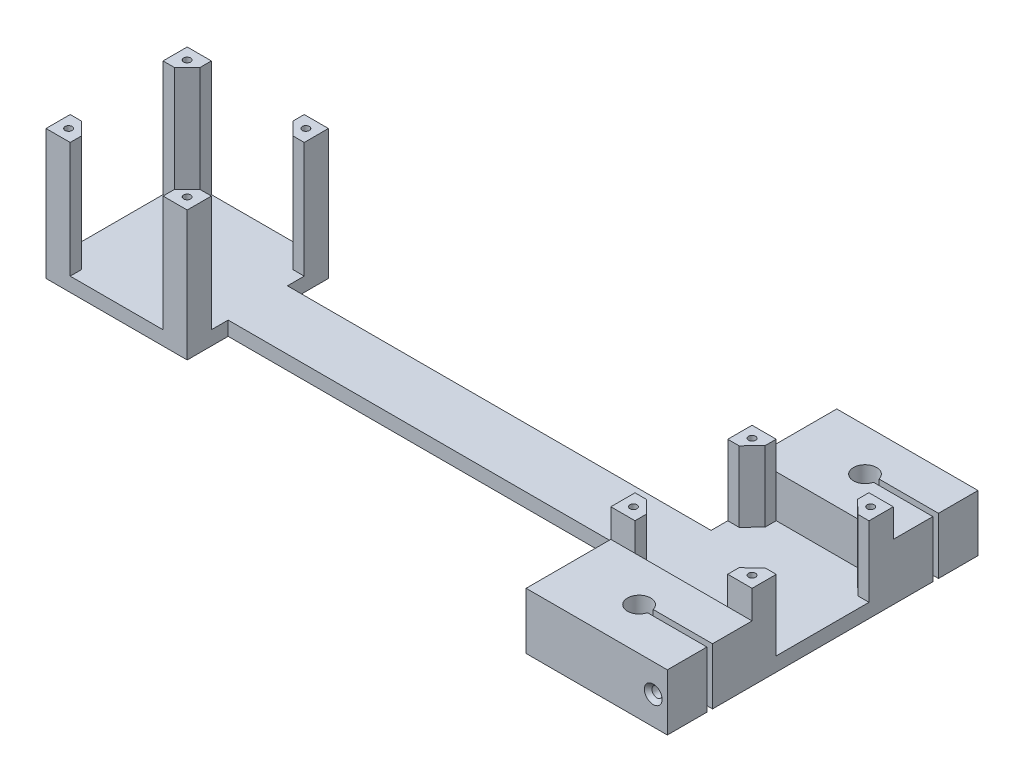
from build123d import *

# Parameters (mm, degrees)
BASE_EXTR_DEPTH                                 = 5
MOTOR_1_EXTR_DEPTH                              = 41
SHAFT_MOTOR_SUPPORT_EXTR_DEPTH                  = 25
TAP_DRILL_FOR_M3X0_5_TAP1_D                     = 2.5
TAP_DRILL_FOR_M3X0_5_TAP1_DEPTH                 = 41
TAP_DRILL_FOR_M3X0_5_TAP1_TIP                   = 0.751075774
BOSS_EXTRUDE10_DEPTH                            = 20
CSK_FOR_M3_OVAL_HEAD_MACHINE_SCREW1_D           = 3.6
CSK_FOR_M3_OVAL_HEAD_MACHINE_SCREW1_DEPTH       = 14
CSK_FOR_M3_OVAL_HEAD_MACHINE_SCREW1_CSINK_D     = 6.3
CSK_FOR_M3_OVAL_HEAD_MACHINE_SCREW1_CSINK_ANGLE = 90
CSK_FOR_M3_OVAL_HEAD_MACHINE_SCREW1_TIP         = 1.081549114
CSK_FOR_M3_OVAL_HEAD_MACHINE_SCREW2_D           = 3.6
CSK_FOR_M3_OVAL_HEAD_MACHINE_SCREW2_DEPTH       = 14
CSK_FOR_M3_OVAL_HEAD_MACHINE_SCREW2_CSINK_D     = 6.3
CSK_FOR_M3_OVAL_HEAD_MACHINE_SCREW2_CSINK_ANGLE = 90
CSK_FOR_M3_OVAL_HEAD_MACHINE_SCREW2_TIP         = 1.081549114
TAP_DRILL_FOR_M3X0_5_TAP2_D                     = 2.5
TAP_DRILL_FOR_M3X0_5_TAP2_DEPTH                 = 14
TAP_DRILL_FOR_M3X0_5_TAP2_TIP                   = 0.751075774
TAP_DRILL_FOR_M3X0_5_TAP3_D                     = 2.5
TAP_DRILL_FOR_M3X0_5_TAP3_DEPTH                 = 14
TAP_DRILL_FOR_M3X0_5_TAP3_TIP                   = 0.751075774


with BuildPart() as part:
    # Base_sch → base_extr (new body)
    with BuildSketch(Plane(origin=(0, 0, 0), x_dir=(1, 0, 0), z_dir=(0, 1, 0))):
        Polygon((25, 10.5), (25, 25), (-25, 25), (-25, -25), (25, -25), (25, -10.5), (175, -10.5), (175, -25), (225.013827764, -25), (225.013827764, 25), (175, 25), (175, 10.5), align=None)
    extrude(amount=BASE_EXTR_DEPTH)

    # motor_support_sch → Motor_1_extr (add)
    with BuildSketch(Plane(origin=(0, 5, 0), x_dir=(1, 0, 0), z_dir=(0, 1, 0))):
        Polygon((-25, 16.439389634), (-25, 25), (-16.439389634, 25), (-16.439389634, 21), (-18.719694817, 18.719694817), (-21, 16.439389634), align=None)
        Polygon((16.439389634, 25), (25, 25), (25, 16.439389634), (21, 16.439389634), (18.719694817, 18.719694817), (16.439389634, 21), align=None)
        Polygon((25, -16.439389634), (25, -25), (16.439389634, -25), (16.439389634, -21), (18.719694817, -18.719694817), (21, -16.439389634), align=None)
        Polygon((-18.719694817, -18.719694817), (-21, -16.439389634), (-25, -16.439389634), (-25, -25), (-16.439389634, -25), (-16.439389634, -21), align=None)
    extrude(amount=MOTOR_1_EXTR_DEPTH)

    # shaft_motor_support_sch → shaft_motor_support_extr (add)
    with BuildSketch(Plane(origin=(0, 5, 0), x_dir=(1, 0, 0), z_dir=(0, 1, 0))):
        Polygon((181.280305183, -18.719694817), (179, -16.439389634), (175, -16.439389634), (175, -25), (183.560610366, -25), (183.560610366, -21), align=None)
        Polygon((175, 25), (175, 16.402508948), (179, 16.402508948), (183.560610366, 21.024047525), (183.560610366, 25), align=None)
        Polygon((225.013827764, -25), (225.013827764, -16.439389634), (221.056642929, -16.439389634), (216.38573482, -21), (216.38573482, -25), align=None)
        Polygon((225.013827764, 25), (216.38573482, 25), (216.38573482, 21.024047525), (221.056642929, 16.402508948), (225.013827764, 16.402508948), align=None)
    extrude(amount=SHAFT_MOTOR_SUPPORT_EXTR_DEPTH)

    # Tap Drill for M3x0.5 Tap1
    with Locations(Plane(origin=(0, 46, 0), x_dir=(1, 0, 0), z_dir=(0, 1, 0))):
        with Locations((-21, -21), (21, -21), (21, 21), (-21, 21), (179.013827764, 21), (221.013827764, 21), (221.013827764, -21), (179.013827764, -21)):
            Hole(TAP_DRILL_FOR_M3X0_5_TAP1_D / 2, depth=TAP_DRILL_FOR_M3X0_5_TAP1_DEPTH)
            with Locations((0, 0, -(TAP_DRILL_FOR_M3X0_5_TAP1_DEPTH + TAP_DRILL_FOR_M3X0_5_TAP1_TIP / 2))):  # 118° drill point
                Cone(0, TAP_DRILL_FOR_M3X0_5_TAP1_D / 2, TAP_DRILL_FOR_M3X0_5_TAP1_TIP, mode=Mode.SUBTRACT)

    # Sketch12 → Boss-Extrude10 (add)
    with BuildSketch(Plane.XZ):
        with BuildLine():
            Line((175, 25), (175, 55))
            Line((175, 55), (225.013827764, 55))
            Line((225.013827764, 55), (225.013827764, 41))
            Line((225.013827764, 41), (203.983092952, 41))
            ThreePointArc((203.983092952, 41), (195.906913882, 40), (203.983092952, 39))
            Line((203.983092952, 39), (225.013827764, 39))
            Line((225.013827764, 39), (225.013827764, 25))
            Line((225.013827764, 25), (175, 25))
        make_face()
        with BuildLine():
            Line((175, -25), (175, -55))
            Line((175, -55), (225.013827764, -55))
            Line((225.013827764, -55), (225.013827764, -41))
            Line((225.013827764, -41), (203.983092952, -41))
            ThreePointArc((203.983092952, -41), (195.906913882, -40), (203.983092952, -39))
            Line((203.983092952, -39), (225.013827764, -39))
            Line((225.013827764, -39), (225.013827764, -25))
            Line((225.013827764, -25), (175, -25))
        make_face()
    extrude(amount=-BOSS_EXTRUDE10_DEPTH)

    # CSK for M3 Oval Head Machine Screw1
    with Locations(Plane(origin=(220.013827764, 10, 55), x_dir=(1, 0, 0), z_dir=(0, 0, 1))):
        with Locations((0, 0)):
            CounterSinkHole(CSK_FOR_M3_OVAL_HEAD_MACHINE_SCREW1_D / 2, CSK_FOR_M3_OVAL_HEAD_MACHINE_SCREW1_CSINK_D / 2, depth=CSK_FOR_M3_OVAL_HEAD_MACHINE_SCREW1_DEPTH, counter_sink_angle=CSK_FOR_M3_OVAL_HEAD_MACHINE_SCREW1_CSINK_ANGLE)
            with Locations((0, 0, -(CSK_FOR_M3_OVAL_HEAD_MACHINE_SCREW1_DEPTH + CSK_FOR_M3_OVAL_HEAD_MACHINE_SCREW1_TIP / 2))):  # 118° drill point
                Cone(0, CSK_FOR_M3_OVAL_HEAD_MACHINE_SCREW1_D / 2, CSK_FOR_M3_OVAL_HEAD_MACHINE_SCREW1_TIP, mode=Mode.SUBTRACT)

    # CSK for M3 Oval Head Machine Screw2
    with Locations(Plane(origin=(220.013827764, 10, -55), x_dir=(-1, 0, 0), z_dir=(0, 0, -1))):
        with Locations((0, 0)):
            CounterSinkHole(CSK_FOR_M3_OVAL_HEAD_MACHINE_SCREW2_D / 2, CSK_FOR_M3_OVAL_HEAD_MACHINE_SCREW2_CSINK_D / 2, depth=CSK_FOR_M3_OVAL_HEAD_MACHINE_SCREW2_DEPTH, counter_sink_angle=CSK_FOR_M3_OVAL_HEAD_MACHINE_SCREW2_CSINK_ANGLE)
            with Locations((0, 0, -(CSK_FOR_M3_OVAL_HEAD_MACHINE_SCREW2_DEPTH + CSK_FOR_M3_OVAL_HEAD_MACHINE_SCREW2_TIP / 2))):  # 118° drill point
                Cone(0, CSK_FOR_M3_OVAL_HEAD_MACHINE_SCREW2_D / 2, CSK_FOR_M3_OVAL_HEAD_MACHINE_SCREW2_TIP, mode=Mode.SUBTRACT)

    # Tap Drill for M3x0.5 Tap2
    with Locations(Plane(origin=(0, 0, -39), x_dir=(-1, 0, 0), z_dir=(0, 0, -1))):
        with Locations((-220.013827764, 10)):
            Hole(TAP_DRILL_FOR_M3X0_5_TAP2_D / 2, depth=TAP_DRILL_FOR_M3X0_5_TAP2_DEPTH)
            with Locations((0, 0, -(TAP_DRILL_FOR_M3X0_5_TAP2_DEPTH + TAP_DRILL_FOR_M3X0_5_TAP2_TIP / 2))):  # 118° drill point
                Cone(0, TAP_DRILL_FOR_M3X0_5_TAP2_D / 2, TAP_DRILL_FOR_M3X0_5_TAP2_TIP, mode=Mode.SUBTRACT)

    # Tap Drill for M3x0.5 Tap3
    with Locations(Plane.XY.offset(39)):
        with Locations((220.013827764, 10)):
            Hole(TAP_DRILL_FOR_M3X0_5_TAP3_D / 2, depth=TAP_DRILL_FOR_M3X0_5_TAP3_DEPTH)
            with Locations((0, 0, -(TAP_DRILL_FOR_M3X0_5_TAP3_DEPTH + TAP_DRILL_FOR_M3X0_5_TAP3_TIP / 2))):  # 118° drill point
                Cone(0, TAP_DRILL_FOR_M3X0_5_TAP3_D / 2, TAP_DRILL_FOR_M3X0_5_TAP3_TIP, mode=Mode.SUBTRACT)


solid = part.part
